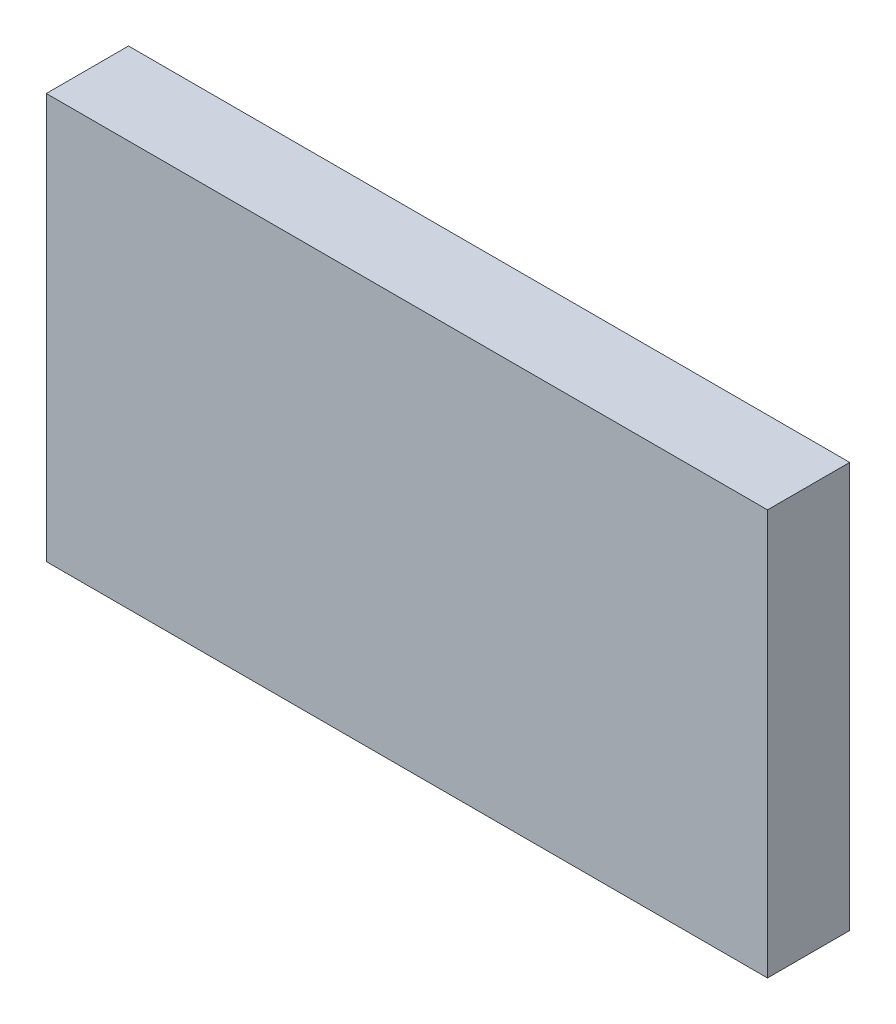
from build123d import *

# Parameters (mm, degrees)
SKETCH2_W      = 87.722336182
SKETCH2_H      = 49.312122507
EXTRUDE1_DEPTH = 10


with BuildPart() as part:
    # Sketch2 → Extrude1 (new body)
    with BuildSketch(Plane.XY):
        with Locations((43.861168091, 24.656061254)):
            Rectangle(SKETCH2_W, SKETCH2_H)
    extrude(amount=EXTRUDE1_DEPTH)


solid = part.part
